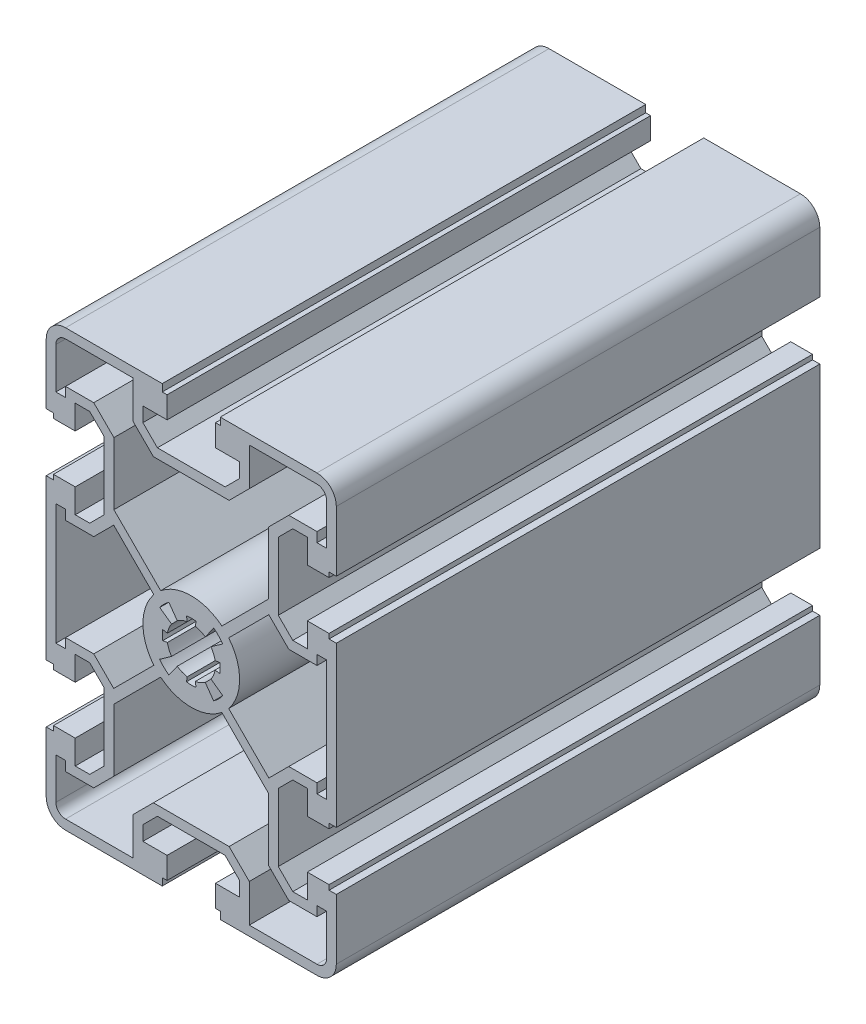
from build123d import *

# Parameters (mm, degrees)
Y_KSEKLIK_EKSTR_ZYON1_DEPTH = 100


with BuildPart() as part:
    # Çizim1 → Yükseklik-Ekstrüzyon1 (new body)
    with BuildSketch(Plane.XY.offset(100)):
        with BuildLine():
            Line((-28.5, 16.5), (-30, 16.5))
            Line((-30, 16.5), (-30, -16.5))
            Line((-30, -16.5), (-28.5, -16.5))
            Line((-28.5, -16.5), (-28.5, -17.5))
            Line((-28.5, -17.5), (-24, -17.5))
            Line((-24, -17.5), (-24, -12.5))
            Line((-24, -12.5), (-21, -12.5))
            Line((-21, -12.5), (-18, -15.5))
            Line((-18, -15.5), (-18, -29.5))
            Line((-18, -29.5), (-21, -32.5))
            Line((-21, -32.5), (-24, -32.5))
            Line((-24, -32.5), (-24, -27.5))
            Line((-24, -27.5), (-28.5, -27.5))
            Line((-28.5, -27.5), (-28.5, -28.5))
            Line((-28.5, -28.5), (-30, -28.5))
            Line((-30, -28.5), (-30, -41))
            ThreePointArc((-30, -41), (-28.828427125, -43.828427125), (-26, -45))
            Line((-26, -45), (-6, -45))
            Line((-6, -45), (-6, -43.5))
            Line((-6, -43.5), (-5, -43.5))
            Line((-5, -43.5), (-5, -39))
            Line((-5, -39), (-10, -39))
            Line((-10, -39), (-10, -36))
            Line((-10, -36), (-7, -33))
            Line((-7, -33), (7, -33))
            Line((7, -33), (10, -36))
            Line((10, -36), (10, -39))
            Line((10, -39), (5, -39))
            Line((5, -39), (5, -43.5))
            Line((5, -43.5), (6, -43.5))
            Line((6, -43.5), (6, -45))
            Line((6, -45), (26, -45))
            ThreePointArc((26, -45), (28.828427125, -43.828427125), (30, -41))
            Line((30, -41), (30, -28.5))
            Line((30, -28.5), (28.5, -28.5))
            Line((28.5, -28.5), (28.5, -27.5))
            Line((28.5, -27.5), (24, -27.5))
            Line((24, -27.5), (24, -32.5))
            Line((24, -32.5), (21, -32.5))
            Line((21, -32.5), (18, -29.5))
            Line((18, -29.5), (18, -15.5))
            Line((18, -15.5), (21, -12.5))
            Line((21, -12.5), (24, -12.5))
            Line((24, -12.5), (24, -17.5))
            Line((24, -17.5), (28.5, -17.5))
            Line((28.5, -17.5), (28.5, -16.5))
            Line((28.5, -16.5), (30, -16.5))
            Line((30, -16.5), (30, 16.5))
            Line((30, 16.5), (28.5, 16.5))
            Line((28.5, 16.5), (28.5, 17.5))
            Line((28.5, 17.5), (24, 17.5))
            Line((24, 17.5), (24, 12.5))
            Line((24, 12.5), (21, 12.5))
            Line((21, 12.5), (18, 15.5))
            Line((18, 15.5), (18, 29.5))
            Line((18, 29.5), (21, 32.5))
            Line((21, 32.5), (24, 32.5))
            Line((24, 32.5), (24, 27.5))
            Line((24, 27.5), (28.5, 27.5))
            Line((28.5, 27.5), (28.5, 28.5))
            Line((28.5, 28.5), (30, 28.5))
            Line((30, 28.5), (30, 41))
            ThreePointArc((30, 41), (28.828427125, 43.828427125), (26, 45))
            Line((26, 45), (6, 45))
            Line((6, 45), (6, 43.5))
            Line((6, 43.5), (5, 43.5))
            Line((5, 43.5), (5, 39))
            Line((5, 39), (10, 39))
            Line((10, 39), (10, 36))
            Line((10, 36), (7, 33))
            Line((7, 33), (-7, 33))
            Line((-7, 33), (-10, 36))
            Line((-10, 36), (-10, 39))
            Line((-10, 39), (-5, 39))
            Line((-5, 39), (-5, 43.5))
            Line((-5, 43.5), (-6, 43.5))
            Line((-6, 43.5), (-6, 45))
            Line((-6, 45), (-26, 45))
            ThreePointArc((-26, 45), (-28.828427125, 43.828427125), (-30, 41))
            Line((-30, 41), (-30, 28.5))
            Line((-30, 28.5), (-28.5, 28.5))
            Line((-28.5, 28.5), (-28.5, 27.5))
            Line((-28.5, 27.5), (-24, 27.5))
            Line((-24, 27.5), (-24, 32.5))
            Line((-24, 32.5), (-21, 32.5))
            Line((-21, 32.5), (-18, 29.5))
            Line((-18, 29.5), (-18, 15.5))
            Line((-18, 15.5), (-21, 12.5))
            Line((-21, 12.5), (-24, 12.5))
            Line((-24, 12.5), (-24, 17.5))
            Line((-24, 17.5), (-28.5, 17.5))
            Line((-28.5, 17.5), (-28.5, 16.5))
        make_face()
        with BuildLine():
            Line((-7.828427125, 31), (7.828427125, 31))
            Line((7.828427125, 31), (12, 35.171572875))
            Line((12, 35.171572875), (12, 43))
            Line((12, 43), (26, 43))
            ThreePointArc((26, 43), (27.414213562, 42.414213562), (28, 41))
            Line((28, 41), (28, 32.5))
            Line((28, 32.5), (26, 32.5))
            Line((26, 32.5), (26, 34.5))
            Line((26, 34.5), (20.171572875, 34.5))
            Line((20.171572875, 34.5), (16, 30.328427125))
            Line((16, 30.328427125), (16, 17.414213562))
            Line((16, 17.414213562), (6.328516859, 7.742730421))
            ThreePointArc((6.328516859, 7.742730421), (0, 10), (-6.328516859, 7.742730421))
            Line((-6.328516859, 7.742730421), (-16, 17.414213562))
            Line((-16, 17.414213562), (-16, 30.328427125))
            Line((-16, 30.328427125), (-20.171572875, 34.5))
            Line((-20.171572875, 34.5), (-26, 34.5))
            Line((-26, 34.5), (-26, 32.5))
            Line((-26, 32.5), (-28, 32.5))
            Line((-28, 32.5), (-28, 41))
            ThreePointArc((-28, 41), (-27.414213562, 42.414213562), (-26, 43))
            Line((-26, 43), (-12, 43))
            Line((-12, 43), (-12, 35.171572875))
            Line((-12, 35.171572875), (-7.828427125, 31))
        make_face(mode=Mode.SUBTRACT)
        with BuildLine():
            Line((7.828427125, -31), (-7.828427125, -31))
            Line((-7.828427125, -31), (-12, -35.171572875))
            Line((-12, -35.171572875), (-12, -43))
            Line((-12, -43), (-26, -43))
            ThreePointArc((-26, -43), (-27.414213562, -42.414213562), (-28, -41))
            Line((-28, -41), (-28, -32.5))
            Line((-28, -32.5), (-26, -32.5))
            Line((-26, -32.5), (-26, -34.5))
            Line((-26, -34.5), (-20.171572875, -34.5))
            Line((-20.171572875, -34.5), (-16, -30.328427125))
            Line((-16, -30.328427125), (-16, -17.414213562))
            Line((-16, -17.414213562), (-6.328516859, -7.742730421))
            ThreePointArc((-6.328516859, -7.742730421), (0, -10), (6.328516859, -7.742730421))
            Line((6.328516859, -7.742730421), (16, -17.414213562))
            Line((16, -17.414213562), (16, -30.328427125))
            Line((16, -30.328427125), (20.171572875, -34.5))
            Line((20.171572875, -34.5), (26, -34.5))
            Line((26, -34.5), (26, -32.5))
            Line((26, -32.5), (28, -32.5))
            Line((28, -32.5), (28, -41))
            ThreePointArc((28, -41), (27.414213562, -42.414213562), (26, -43))
            Line((26, -43), (12, -43))
            Line((12, -43), (12, -35.171572875))
            Line((12, -35.171572875), (7.828427125, -31))
        make_face(mode=Mode.SUBTRACT)
        with BuildLine():
            Line((7.742730421, 6.328516859), (16.042893219, 14.628679656))
            Line((16.042893219, 14.628679656), (20.171572875, 10.5))
            Line((20.171572875, 10.5), (26, 10.5))
            Line((26, 10.5), (26, 12.5))
            Line((26, 12.5), (28, 12.5))
            Line((28, 12.5), (28, -12.5))
            Line((28, -12.5), (26, -12.5))
            Line((26, -12.5), (26, -10.5))
            Line((26, -10.5), (20.171572875, -10.5))
            Line((20.171572875, -10.5), (16.042893219, -14.628679656))
            Line((16.042893219, -14.628679656), (7.742730421, -6.328516859))
            ThreePointArc((7.742730421, -6.328516859), (10, 0), (7.742730421, 6.328516859))
        make_face(mode=Mode.SUBTRACT)
        with BuildLine():
            Line((-7.742730421, -6.328516859), (-16.042893219, -14.628679656))
            Line((-16.042893219, -14.628679656), (-20.171572875, -10.5))
            Line((-20.171572875, -10.5), (-26, -10.5))
            Line((-26, -10.5), (-26, -12.5))
            Line((-26, -12.5), (-28, -12.5))
            Line((-28, -12.5), (-28, 12.5))
            Line((-28, 12.5), (-26, 12.5))
            Line((-26, 12.5), (-26, 10.5))
            Line((-26, 10.5), (-20.171572875, 10.5))
            Line((-20.171572875, 10.5), (-16.042893219, 14.628679656))
            Line((-16.042893219, 14.628679656), (-7.742730421, 6.328516859))
            ThreePointArc((-7.742730421, 6.328516859), (-10, 0), (-7.742730421, -6.328516859))
        make_face(mode=Mode.SUBTRACT)
        with BuildLine():
            Line((4.635387441, -6.520213438), (2.897117156, -4.075133406))
            ThreePointArc((2.897117156, -4.075133406), (1.91341717, -4.619397669), (0.832983289, -4.930125651))
            Line((0.832983289, -4.930125651), (0.999579948, -5.916150785))
            ThreePointArc((0.999579948, -5.916150785), (8e-09, -6.000000015), (-0.999579931, -5.916150788))
            Line((-0.999579931, -5.916150788), (-0.832983276, -4.930125653))
            ThreePointArc((-0.832983276, -4.930125653), (-1.913417184, -4.619397663), (-2.897117191, -4.075133381))
            Line((-2.897117191, -4.075133381), (-4.635387497, -6.520213398))
            ThreePointArc((-4.635387497, -6.520213398), (-5.656854273, -5.656854226), (-6.520213436, -4.635387443))
            Line((-6.520213436, -4.635387443), (-4.075133405, -2.897117157))
            ThreePointArc((-4.075133405, -2.897117157), (-4.619397669, -1.913417171), (-4.930125651, -0.832983289))
            Line((-4.930125651, -0.832983289), (-5.916150785, -0.999579947))
            ThreePointArc((-5.916150785, -0.999579947), (-6.000000015, -8e-09), (-5.916150787, 0.999579932))
            Line((-5.916150787, 0.999579932), (-4.930125653, 0.832983276))
            ThreePointArc((-4.930125653, 0.832983276), (-4.619397671, 1.913417165), (-4.075133405, 2.897117157))
            Line((-4.075133405, 2.897117157), (-6.520213437, 4.635387442))
            ThreePointArc((-6.520213437, 4.635387442), (-5.656854249, 5.65685425), (-4.635387441, 6.520213438))
            Line((-4.635387441, 6.520213438), (-2.897117156, 4.075133406))
            ThreePointArc((-2.897117156, 4.075133406), (-1.913417164, 4.619397671), (-0.832983276, 4.930125653))
            Line((-0.832983276, 4.930125653), (-0.999579932, 5.916150788))
            ThreePointArc((-0.999579932, 5.916150788), (8e-09, 6.000000015), (0.999579947, 5.916150785))
            Line((0.999579947, 5.916150785), (0.832983289, 4.930125651))
            ThreePointArc((0.832983289, 4.930125651), (1.91341719, 4.619397661), (2.897117191, 4.075133381))
            Line((2.897117191, 4.075133381), (4.635387497, 6.520213398))
            ThreePointArc((4.635387497, 6.520213398), (5.656854273, 5.656854226), (6.520213436, 4.635387443))
            Line((6.520213436, 4.635387443), (4.075133405, 2.897117157))
            ThreePointArc((4.075133405, 2.897117157), (4.619397671, 1.913417164), (4.930125653, 0.832983275))
            Line((4.930125653, 0.832983275), (5.916150788, 0.999579931))
            ThreePointArc((5.916150788, 0.999579931), (6.000000015, 0), (5.916150788, -0.99957993))
            Line((5.916150788, -0.99957993), (4.930125653, -0.832983275))
            ThreePointArc((4.930125653, -0.832983275), (4.619397671, -1.913417164), (4.075133405, -2.897117157))
            Line((4.075133405, -2.897117157), (6.520213437, -4.635387442))
            ThreePointArc((6.520213437, -4.635387442), (5.656854249, -5.65685425), (4.635387441, -6.520213438))
        make_face(mode=Mode.SUBTRACT)
    extrude(amount=-Y_KSEKLIK_EKSTR_ZYON1_DEPTH)


solid = part.part
